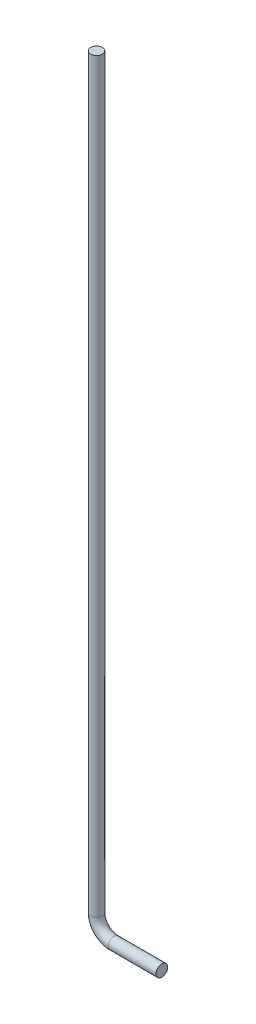
from build123d import *

# Parameters (mm, degrees)
SKETCH1_R           = 1.5875
BOSS_EXTRUDE1_DEPTH = 203.2
SKETCH3_R           = 1.5875


with BuildPart() as part:
    # Sketch1 → Boss-Extrude1 (new body)
    with BuildSketch(Plane(origin=(0, 0, 0), x_dir=(1, 0, 0), z_dir=(0, 1, 0))):
        with Locations((-12.7, 0)):
            Circle(SKETCH1_R)
    extrude(amount=-BOSS_EXTRUDE1_DEPTH)

    # Sweep1: sweep along a path in Sketch2
    with BuildLine(Plane.XY) as sweep1_path:
        Line((5.08, -207.9625), (-7.9375, -207.9625))
        ThreePointArc((-7.9375, -207.9625), (-11.305096045, -206.567596045), (-12.7, -203.2))
    # Sketch3 → Sweep1 (sweep)
    with BuildSketch(Plane(origin=(5.08, 0, 0), x_dir=(0, 0, -1), z_dir=(1, 0, 0))):
        with Locations((0, -207.9625)):
            Circle(SKETCH3_R)
    sweep(path=sweep1_path.line)


solid = part.part
